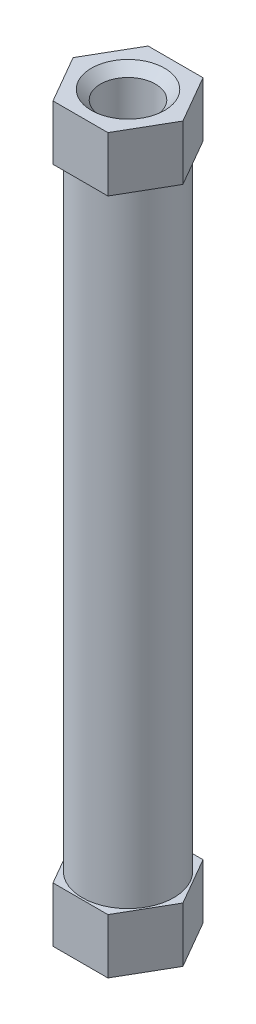
from build123d import *

# Parameters (mm, degrees)
BOSS_EXTRUDE1_DEPTH = 3
SKETCH2_R           = 2.5
BOSS_EXTRUDE2_DEPTH = 34
BOSS_EXTRUDE3_DEPTH = 3
SKETCH4_R           = 1.5
CUT_EXTRUDE1_DEPTH  = 41
CHAMFER1_SIZE       = 0.5


with BuildPart() as part:
    # Sketch1 → Boss-Extrude1 (new body)
    with BuildSketch(Plane(origin=(0, 0, 0), x_dir=(1, 0, 0), z_dir=(0, 1, 0))):
        Polygon((1.5, -2.598076211), (3, 0), (1.5, 2.598076211), (-1.5, 2.598076211), (-3, 0), (-1.5, -2.598076211), align=None)
    extrude(amount=BOSS_EXTRUDE1_DEPTH)

    # Sketch2 → Boss-Extrude2 (add)
    with BuildSketch(Plane(origin=(0, 3, 0), x_dir=(1, 0, 0), z_dir=(0, 1, 0))):
        Circle(SKETCH2_R)
    extrude(amount=BOSS_EXTRUDE2_DEPTH)

    # Sketch3 → Boss-Extrude3 (add)
    with BuildSketch(Plane(origin=(0, 37, 0), x_dir=(1, 0, 0), z_dir=(0, 1, 0))):
        Polygon((1.5, -2.598076211), (3, 0), (1.5, 2.598076211), (-1.5, 2.598076211), (-3, 0), (-1.5, -2.598076211), align=None)
    extrude(amount=BOSS_EXTRUDE3_DEPTH)

    # Sketch4 → Cut-Extrude1 (cut, through all)
    with BuildSketch(Plane(origin=(0, 40, 0), x_dir=(1, 0, 0), z_dir=(0, 1, 0))):
        Circle(SKETCH4_R)
    extrude(amount=-CUT_EXTRUDE1_DEPTH, mode=Mode.SUBTRACT)

    # Chamfer1
    chamfer1_edges = [part.edges().sort_by_distance(p)[0] for p in [
        (-1.5, 0, 0),
        (-1.5, 40, 0),
    ]]
    chamfer(chamfer1_edges, length=CHAMFER1_SIZE)


solid = part.part
